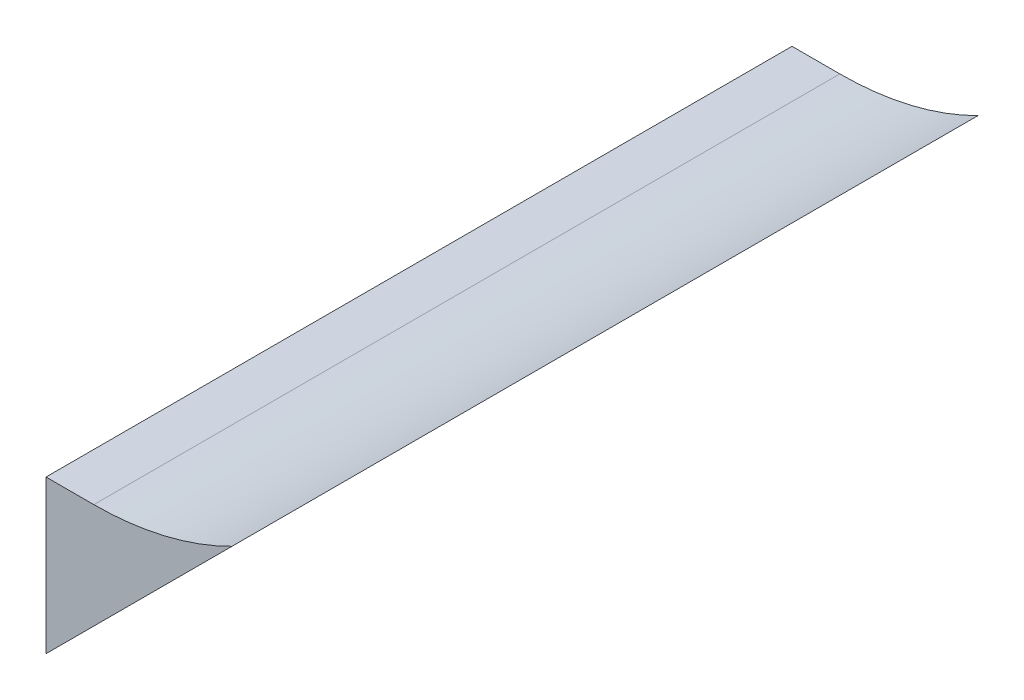
from build123d import *

# Parameters (mm, degrees)
EXTRUDE_1_DEPTH = 39


with BuildPart() as part:
    # Эскиз1 → Вытянуть1 (new body)
    with BuildSketch(Plane.XY):
        with BuildLine():
            Line((-323.5, 0), (-323.5, -8))
            Line((-323.5, -8), (-315.5, 0))
            Line((-315.5, 0), (-313.77668374, 1.72331626))
            ThreePointArc((-313.77668374, 1.72331626), (-317.286978417, 0.436791117), (-321, 0))
            Line((-321, 0), (-323.5, 0))
        make_face()
    extrude(amount=-EXTRUDE_1_DEPTH)


solid = part.part
